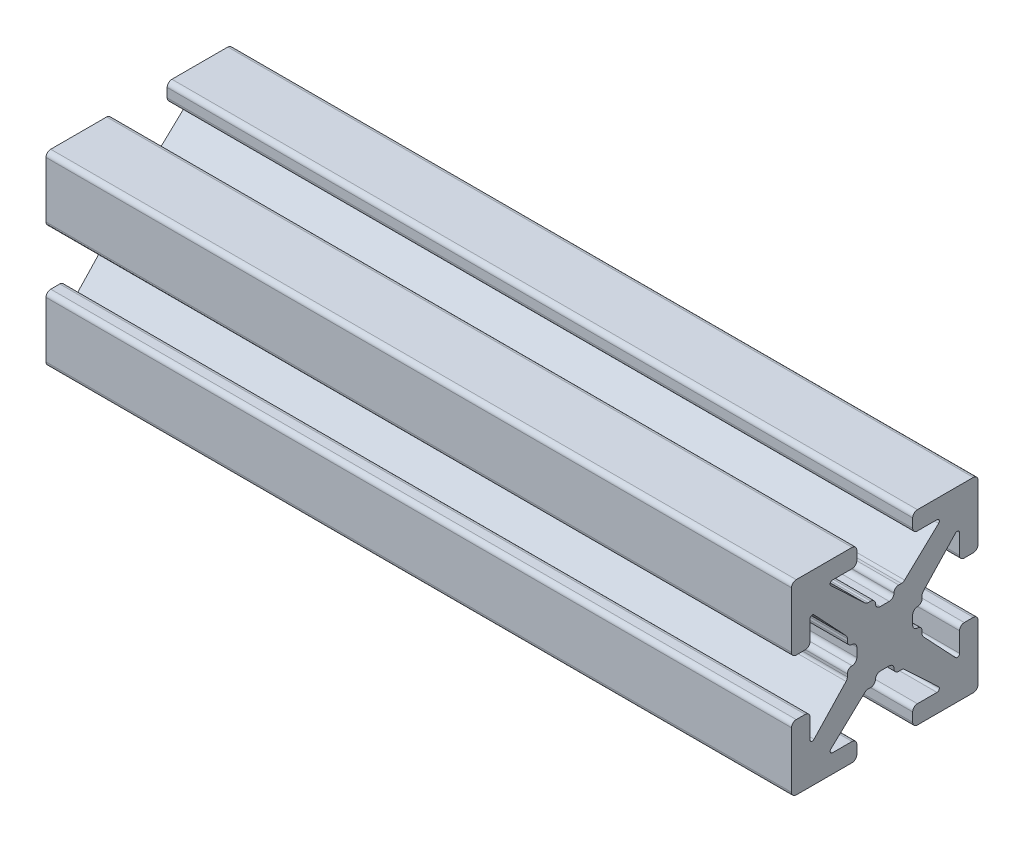
from build123d import *

# Parameters (mm, degrees)
BOSS_EXTRU_1_DEPTH = 40


with BuildPart() as part:
    # Sketch1 → Boss.-Extru.1 (new body)
    with BuildSketch(Plane(origin=(0, 0, 0), x_dir=(0, 0, -1), z_dir=(1, 0, 0))):
        with BuildLine():
            Line((-0.2413, 1.4986), (0.2413, 1.4986))
            ThreePointArc((0.2413, 1.4986), (0.420905122, 1.572994878), (0.4953, 1.7526))
            ThreePointArc((0.4953, 1.7526), (0.569694878, 1.932205122), (0.7493, 2.0066))
            Line((0.7493, 2.0066), (0.889923986, 2.0066))
            ThreePointArc((0.889923986, 2.0066), (0.983516259, 2.024471886), (1.063937899, 2.075572548))
            Line((1.063937899, 2.075572548), (2.890793, 3.793686274))
            ThreePointArc((2.890793, 3.793686274), (2.921850101, 3.932996137), (2.803786044, 4.0132))
            Line((2.803786044, 4.0132), (1.7526, 4.0132))
            ThreePointArc((1.7526, 4.0132), (1.572994878, 4.087594878), (1.4986, 4.2672))
            Line((1.4986, 4.2672), (1.4986, 4.7498))
            ThreePointArc((1.4986, 4.7498), (1.572994878, 4.929405122), (1.7526, 5.0038))
            Line((1.7526, 5.0038), (4.7498, 5.0038))
            ThreePointArc((4.7498, 5.0038), (4.929405122, 4.929405122), (5.0038, 4.7498))
            Line((5.0038, 4.7498), (5.0038, 1.7526))
            ThreePointArc((5.0038, 1.7526), (4.929405122, 1.572994878), (4.7498, 1.4986))
            Line((4.7498, 1.4986), (4.2672, 1.4986))
            ThreePointArc((4.2672, 1.4986), (4.087594878, 1.572994878), (4.0132, 1.7526))
            Line((4.0132, 1.7526), (4.0132, 2.803786044))
            ThreePointArc((4.0132, 2.803786044), (3.932996137, 2.921850101), (3.793686274, 2.890793))
            Line((3.793686274, 2.890793), (2.075572548, 1.063937899))
            ThreePointArc((2.075572548, 1.063937899), (2.024471886, 0.983516259), (2.0066, 0.889923986))
            Line((2.0066, 0.889923986), (2.0066, 0.7493))
            ThreePointArc((2.0066, 0.7493), (1.932205122, 0.569694878), (1.7526, 0.4953))
            ThreePointArc((1.7526, 0.4953), (1.572994878, 0.420905122), (1.4986, 0.2413))
            Line((1.4986, 0.2413), (1.4986, -0.2413))
            ThreePointArc((1.4986, -0.2413), (1.572994878, -0.420905122), (1.7526, -0.4953))
            ThreePointArc((1.7526, -0.4953), (1.932205122, -0.569694878), (2.0066, -0.7493))
            Line((2.0066, -0.7493), (2.0066, -0.889923986))
            ThreePointArc((2.0066, -0.889923986), (2.024471886, -0.983516259), (2.075572548, -1.063937899))
            Line((2.075572548, -1.063937899), (3.793686274, -2.890793))
            ThreePointArc((3.793686274, -2.890793), (3.932996137, -2.921850101), (4.0132, -2.803786044))
            Line((4.0132, -2.803786044), (4.0132, -1.7526))
            ThreePointArc((4.0132, -1.7526), (4.087594878, -1.572994878), (4.2672, -1.4986))
            Line((4.2672, -1.4986), (4.7498, -1.4986))
            ThreePointArc((4.7498, -1.4986), (4.929405122, -1.572994878), (5.0038, -1.7526))
            Line((5.0038, -1.7526), (5.0038, -4.7498))
            ThreePointArc((5.0038, -4.7498), (4.929405122, -4.929405122), (4.7498, -5.0038))
            Line((4.7498, -5.0038), (1.7526, -5.0038))
            ThreePointArc((1.7526, -5.0038), (1.572994878, -4.929405122), (1.4986, -4.7498))
            Line((1.4986, -4.7498), (1.4986, -4.2672))
            ThreePointArc((1.4986, -4.2672), (1.572994878, -4.087594878), (1.7526, -4.0132))
            Line((1.7526, -4.0132), (2.803786044, -4.0132))
            ThreePointArc((2.803786044, -4.0132), (2.921850101, -3.932996137), (2.890793, -3.793686274))
            Line((2.890793, -3.793686274), (1.063937899, -2.075572548))
            ThreePointArc((1.063937899, -2.075572548), (0.983516259, -2.024471886), (0.889923986, -2.0066))
            Line((0.889923986, -2.0066), (0.7493, -2.0066))
            ThreePointArc((0.7493, -2.0066), (0.569694878, -1.932205122), (0.4953, -1.7526))
            ThreePointArc((0.4953, -1.7526), (0.420905122, -1.572994878), (0.2413, -1.4986))
            Line((0.2413, -1.4986), (-0.2413, -1.4986))
            ThreePointArc((-0.2413, -1.4986), (-0.420905122, -1.572994878), (-0.4953, -1.7526))
            ThreePointArc((-0.4953, -1.7526), (-0.569694878, -1.932205122), (-0.7493, -2.0066))
            Line((-0.7493, -2.0066), (-0.889923986, -2.0066))
            ThreePointArc((-0.889923986, -2.0066), (-0.983516259, -2.024471886), (-1.063937899, -2.075572548))
            Line((-1.063937899, -2.075572548), (-2.890793, -3.793686274))
            ThreePointArc((-2.890793, -3.793686274), (-2.921850101, -3.932996137), (-2.803786044, -4.0132))
            Line((-2.803786044, -4.0132), (-1.7526, -4.0132))
            ThreePointArc((-1.7526, -4.0132), (-1.572994878, -4.087594878), (-1.4986, -4.2672))
            Line((-1.4986, -4.2672), (-1.4986, -4.7498))
            ThreePointArc((-1.4986, -4.7498), (-1.572994878, -4.929405122), (-1.7526, -5.0038))
            Line((-1.7526, -5.0038), (-4.7498, -5.0038))
            ThreePointArc((-4.7498, -5.0038), (-4.929405122, -4.929405122), (-5.0038, -4.7498))
            Line((-5.0038, -4.7498), (-5.0038, -1.7526))
            ThreePointArc((-5.0038, -1.7526), (-4.929405122, -1.572994878), (-4.7498, -1.4986))
            Line((-4.7498, -1.4986), (-4.2672, -1.4986))
            ThreePointArc((-4.2672, -1.4986), (-4.087594878, -1.572994878), (-4.0132, -1.7526))
            Line((-4.0132, -1.7526), (-4.0132, -2.803786044))
            ThreePointArc((-4.0132, -2.803786044), (-3.932996137, -2.921850101), (-3.793686274, -2.890793))
            Line((-3.793686274, -2.890793), (-2.075572548, -1.063937899))
            ThreePointArc((-2.075572548, -1.063937899), (-2.024471886, -0.983516259), (-2.0066, -0.889923986))
            Line((-2.0066, -0.889923986), (-2.0066, -0.7493))
            ThreePointArc((-2.0066, -0.7493), (-1.932205122, -0.569694878), (-1.7526, -0.4953))
            ThreePointArc((-1.7526, -0.4953), (-1.572994878, -0.420905122), (-1.4986, -0.2413))
            Line((-1.4986, -0.2413), (-1.4986, 0.2413))
            ThreePointArc((-1.4986, 0.2413), (-1.572994878, 0.420905122), (-1.7526, 0.4953))
            ThreePointArc((-1.7526, 0.4953), (-1.932205122, 0.569694878), (-2.0066, 0.7493))
            Line((-2.0066, 0.7493), (-2.0066, 0.889923986))
            ThreePointArc((-2.0066, 0.889923986), (-2.024471886, 0.983516259), (-2.075572548, 1.063937899))
            Line((-2.075572548, 1.063937899), (-3.793686274, 2.890793))
            ThreePointArc((-3.793686274, 2.890793), (-3.932996137, 2.921850101), (-4.0132, 2.803786044))
            Line((-4.0132, 2.803786044), (-4.0132, 1.7526))
            ThreePointArc((-4.0132, 1.7526), (-4.087594878, 1.572994878), (-4.2672, 1.4986))
            Line((-4.2672, 1.4986), (-4.7498, 1.4986))
            ThreePointArc((-4.7498, 1.4986), (-4.929405122, 1.572994878), (-5.0038, 1.7526))
            Line((-5.0038, 1.7526), (-5.0038, 4.7498))
            ThreePointArc((-5.0038, 4.7498), (-4.929405122, 4.929405122), (-4.7498, 5.0038))
            Line((-4.7498, 5.0038), (-1.7526, 5.0038))
            ThreePointArc((-1.7526, 5.0038), (-1.572994878, 4.929405122), (-1.4986, 4.7498))
            Line((-1.4986, 4.7498), (-1.4986, 4.2672))
            ThreePointArc((-1.4986, 4.2672), (-1.572994878, 4.087594878), (-1.7526, 4.0132))
            Line((-1.7526, 4.0132), (-2.803786044, 4.0132))
            ThreePointArc((-2.803786044, 4.0132), (-2.921850101, 3.932996137), (-2.890793, 3.793686274))
            Line((-2.890793, 3.793686274), (-1.063937899, 2.075572548))
            ThreePointArc((-1.063937899, 2.075572548), (-0.983516259, 2.024471886), (-0.889923986, 2.0066))
            Line((-0.889923986, 2.0066), (-0.7493, 2.0066))
            ThreePointArc((-0.7493, 2.0066), (-0.569694878, 1.932205122), (-0.4953, 1.7526))
            ThreePointArc((-0.4953, 1.7526), (-0.420905122, 1.572994878), (-0.2413, 1.4986))
        make_face()
    extrude(amount=BOSS_EXTRU_1_DEPTH)


solid = part.part
